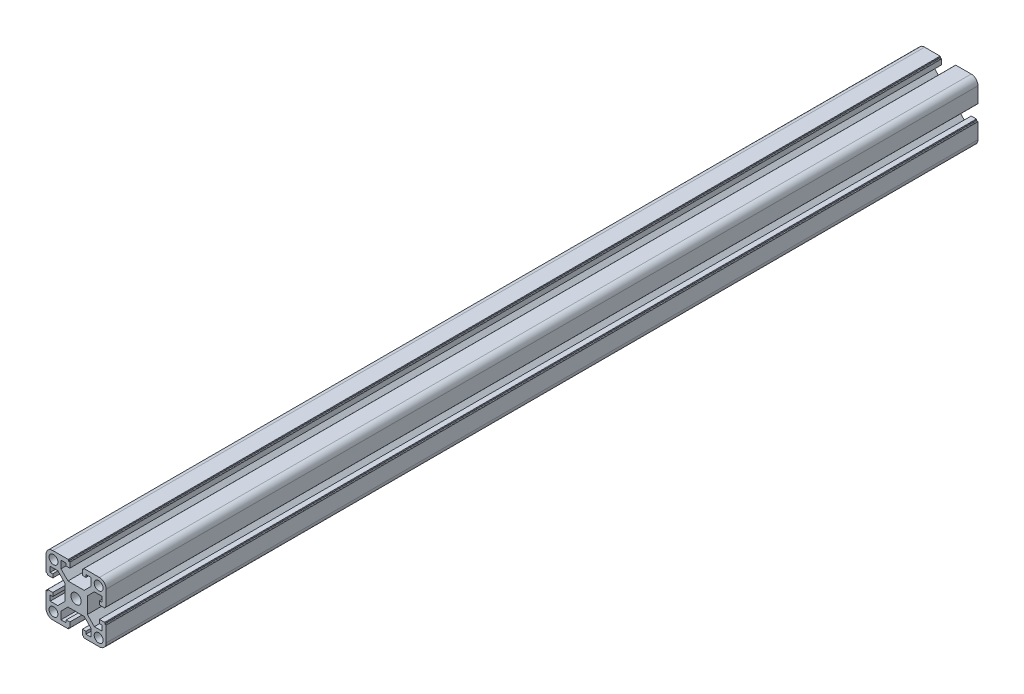
from build123d import *

# Parameters (mm, degrees)
SKETCH_1_R      = 2.95
SKETCH_1_R_2    = 3.4
EXTRUDE_1_DEPTH = 290


with BuildPart() as part:
    # 草图1 → 凸台-拉伸1 (new body, symmetric)
    with BuildSketch(Plane.XY.offset(50)):
        with BuildLine():
            Line((-1518.245004392, 3588.004280474), (-1518.245004392, 3582.975600817))
            Line((-1518.245004392, 3582.975600817), (-1522.916324736, 3578.304280474))
            Line((-1522.916324736, 3578.304280474), (-1533.673684048, 3578.304280474))
            Line((-1533.673684048, 3578.304280474), (-1538.345004392, 3582.975600817))
            Line((-1538.345004392, 3582.975600817), (-1538.345004392, 3588.004280474))
            Line((-1538.345004392, 3588.004280474), (-1534.845004392, 3588.004280474))
            Line((-1534.845004392, 3588.004280474), (-1534.845004392, 3586.304280474))
            Line((-1534.845004392, 3586.304280474), (-1532.445004392, 3586.304280474))
            Line((-1532.445004392, 3586.304280474), (-1532.445004392, 3589.704280474))
            ThreePointArc((-1532.445004392, 3589.704280474), (-1532.503583036, 3589.84570183), (-1532.645004392, 3589.904280474))
            Line((-1532.645004392, 3589.904280474), (-1533.345004392, 3589.904280474))
            Line((-1533.345004392, 3589.904280474), (-1533.345004392, 3590.604280474))
            ThreePointArc((-1533.345004392, 3590.604280474), (-1533.403583036, 3590.74570183), (-1533.545004392, 3590.804280474))
            Line((-1533.545004392, 3590.804280474), (-1543.795004392, 3590.804280474))
            ThreePointArc((-1543.795004392, 3590.804280474), (-1546.976984907, 3589.486260989), (-1548.295004392, 3586.304280474))
            Line((-1548.295004392, 3586.304280474), (-1548.295004392, 3576.054280474))
            ThreePointArc((-1548.295004392, 3576.054280474), (-1548.236425748, 3575.912859117), (-1548.095004392, 3575.854280474))
            Line((-1548.095004392, 3575.854280474), (-1547.395004392, 3575.854280474))
            Line((-1547.395004392, 3575.854280474), (-1547.395004392, 3575.154280474))
            ThreePointArc((-1547.395004392, 3575.154280474), (-1547.336425748, 3575.012859117), (-1547.195004392, 3574.954280474))
            Line((-1547.195004392, 3574.954280474), (-1543.795004392, 3574.954280474))
            Line((-1543.795004392, 3574.954280474), (-1543.795004392, 3577.354280474))
            Line((-1543.795004392, 3577.354280474), (-1545.495004392, 3577.354280474))
            Line((-1545.495004392, 3577.354280474), (-1545.495004392, 3580.854280474))
            Line((-1545.495004392, 3580.854280474), (-1540.466324736, 3580.854280474))
            Line((-1540.466324736, 3580.854280474), (-1535.795004392, 3576.18296013))
            Line((-1535.795004392, 3576.18296013), (-1535.795004392, 3565.425600817))
            Line((-1535.795004392, 3565.425600817), (-1540.466324736, 3560.754280474))
            Line((-1540.466324736, 3560.754280474), (-1545.495004392, 3560.754280474))
            Line((-1545.495004392, 3560.754280474), (-1545.495004392, 3564.254280474))
            Line((-1545.495004392, 3564.254280474), (-1543.795004392, 3564.254280474))
            Line((-1543.795004392, 3564.254280474), (-1543.795004392, 3566.654280474))
            Line((-1543.795004392, 3566.654280474), (-1547.195004392, 3566.654280474))
            ThreePointArc((-1547.195004392, 3566.654280474), (-1547.336425748, 3566.59570183), (-1547.395004392, 3566.454280474))
            Line((-1547.395004392, 3566.454280474), (-1547.395004392, 3565.754280474))
            Line((-1547.395004392, 3565.754280474), (-1548.095004392, 3565.754280474))
            ThreePointArc((-1548.095004392, 3565.754280474), (-1548.236425748, 3565.69570183), (-1548.295004392, 3565.554280474))
            Line((-1548.295004392, 3565.554280474), (-1548.295004392, 3555.304280474))
            ThreePointArc((-1548.295004392, 3555.304280474), (-1546.976984907, 3552.122299958), (-1543.795004392, 3550.804280474))
            Line((-1543.795004392, 3550.804280474), (-1533.545004392, 3550.804280474))
            ThreePointArc((-1533.545004392, 3550.804280474), (-1533.403583036, 3550.862859117), (-1533.345004392, 3551.004280474))
            Line((-1533.345004392, 3551.004280474), (-1533.345004392, 3551.704280474))
            Line((-1533.345004392, 3551.704280474), (-1532.645004392, 3551.704280474))
            ThreePointArc((-1532.645004392, 3551.704280474), (-1532.503583036, 3551.762859117), (-1532.445004392, 3551.904280474))
            Line((-1532.445004392, 3551.904280474), (-1532.445004392, 3555.304280474))
            Line((-1532.445004392, 3555.304280474), (-1534.845004392, 3555.304280474))
            Line((-1534.845004392, 3555.304280474), (-1534.845004392, 3553.604280474))
            Line((-1534.845004392, 3553.604280474), (-1538.345004392, 3553.604280474))
            Line((-1538.345004392, 3553.604280474), (-1538.345004392, 3558.63296013))
            Line((-1538.345004392, 3558.63296013), (-1533.673684048, 3563.304280474))
            Line((-1533.673684048, 3563.304280474), (-1522.916324736, 3563.304280474))
            Line((-1522.916324736, 3563.304280474), (-1518.245004392, 3558.63296013))
            Line((-1518.245004392, 3558.63296013), (-1518.245004392, 3553.604280474))
            Line((-1518.245004392, 3553.604280474), (-1521.745004392, 3553.604280474))
            Line((-1521.745004392, 3553.604280474), (-1521.745004392, 3555.304280474))
            Line((-1521.745004392, 3555.304280474), (-1524.145004392, 3555.304280474))
            Line((-1524.145004392, 3555.304280474), (-1524.145004392, 3551.904280474))
            ThreePointArc((-1524.145004392, 3551.904280474), (-1524.086425748, 3551.762859117), (-1523.945004392, 3551.704280474))
            Line((-1523.945004392, 3551.704280474), (-1523.245004392, 3551.704280474))
            Line((-1523.245004392, 3551.704280474), (-1523.245004392, 3551.004280474))
            ThreePointArc((-1523.245004392, 3551.004280474), (-1523.186425748, 3550.862859117), (-1523.045004392, 3550.804280474))
            Line((-1523.045004392, 3550.804280474), (-1512.795004392, 3550.804280474))
            ThreePointArc((-1512.795004392, 3550.804280474), (-1509.613023877, 3552.122299958), (-1508.295004392, 3555.304280474))
            Line((-1508.295004392, 3555.304280474), (-1508.295004392, 3565.554280474))
            ThreePointArc((-1508.295004392, 3565.554280474), (-1508.353583036, 3565.69570183), (-1508.495004392, 3565.754280474))
            Line((-1508.495004392, 3565.754280474), (-1509.195004392, 3565.754280474))
            Line((-1509.195004392, 3565.754280474), (-1509.195004392, 3566.454280474))
            ThreePointArc((-1509.195004392, 3566.454280474), (-1509.253583036, 3566.59570183), (-1509.395004392, 3566.654280474))
            Line((-1509.395004392, 3566.654280474), (-1512.795004392, 3566.654280474))
            Line((-1512.795004392, 3566.654280474), (-1512.795004392, 3564.254280474))
            Line((-1512.795004392, 3564.254280474), (-1511.095004392, 3564.254280474))
            Line((-1511.095004392, 3564.254280474), (-1511.095004392, 3560.754280474))
            Line((-1511.095004392, 3560.754280474), (-1516.123684048, 3560.754280474))
            Line((-1516.123684048, 3560.754280474), (-1520.795004392, 3565.425600817))
            Line((-1520.795004392, 3565.425600817), (-1520.795004392, 3576.18296013))
            Line((-1520.795004392, 3576.18296013), (-1516.123684048, 3580.854280474))
            Line((-1516.123684048, 3580.854280474), (-1511.095004392, 3580.854280474))
            Line((-1511.095004392, 3580.854280474), (-1511.095004392, 3577.354280474))
            Line((-1511.095004392, 3577.354280474), (-1512.795004392, 3577.354280474))
            Line((-1512.795004392, 3577.354280474), (-1512.795004392, 3574.954280474))
            Line((-1512.795004392, 3574.954280474), (-1509.395004392, 3574.954280474))
            ThreePointArc((-1509.395004392, 3574.954280474), (-1509.253583036, 3575.012859117), (-1509.195004392, 3575.154280474))
            Line((-1509.195004392, 3575.154280474), (-1509.195004392, 3575.854280474))
            Line((-1509.195004392, 3575.854280474), (-1508.495004392, 3575.854280474))
            ThreePointArc((-1508.495004392, 3575.854280474), (-1508.353583036, 3575.912859117), (-1508.295004392, 3576.054280474))
            Line((-1508.295004392, 3576.054280474), (-1508.295004392, 3586.304280474))
            ThreePointArc((-1508.295004392, 3586.304280474), (-1509.613023877, 3589.486260989), (-1512.795004392, 3590.804280474))
            Line((-1512.795004392, 3590.804280474), (-1523.045004392, 3590.804280474))
            ThreePointArc((-1523.045004392, 3590.804280474), (-1523.186425748, 3590.74570183), (-1523.245004392, 3590.604280474))
            Line((-1523.245004392, 3590.604280474), (-1523.245004392, 3589.904280474))
            Line((-1523.245004392, 3589.904280474), (-1523.945004392, 3589.904280474))
            ThreePointArc((-1523.945004392, 3589.904280474), (-1524.086425748, 3589.84570183), (-1524.145004392, 3589.704280474))
            Line((-1524.145004392, 3589.704280474), (-1524.145004392, 3586.304280474))
            Line((-1524.145004392, 3586.304280474), (-1521.745004392, 3586.304280474))
            Line((-1521.745004392, 3586.304280474), (-1521.745004392, 3588.004280474))
            Line((-1521.745004392, 3588.004280474), (-1518.245004392, 3588.004280474))
        make_face()
        with Locations((-1513.270004392, 3555.779280474)):
            Circle(SKETCH_1_R, mode=Mode.SUBTRACT)
        with Locations((-1528.295004392, 3570.804280474)):
            Circle(SKETCH_1_R_2, mode=Mode.SUBTRACT)
        with Locations((-1513.270004392, 3585.829280474)):
            Circle(SKETCH_1_R, mode=Mode.SUBTRACT)
        with Locations((-1543.320004392, 3585.829280474)):
            Circle(SKETCH_1_R, mode=Mode.SUBTRACT)
        with Locations((-1543.320004392, 3555.779280474)):
            Circle(SKETCH_1_R, mode=Mode.SUBTRACT)
    extrude(amount=EXTRUDE_1_DEPTH, both=True)


solid = part.part
